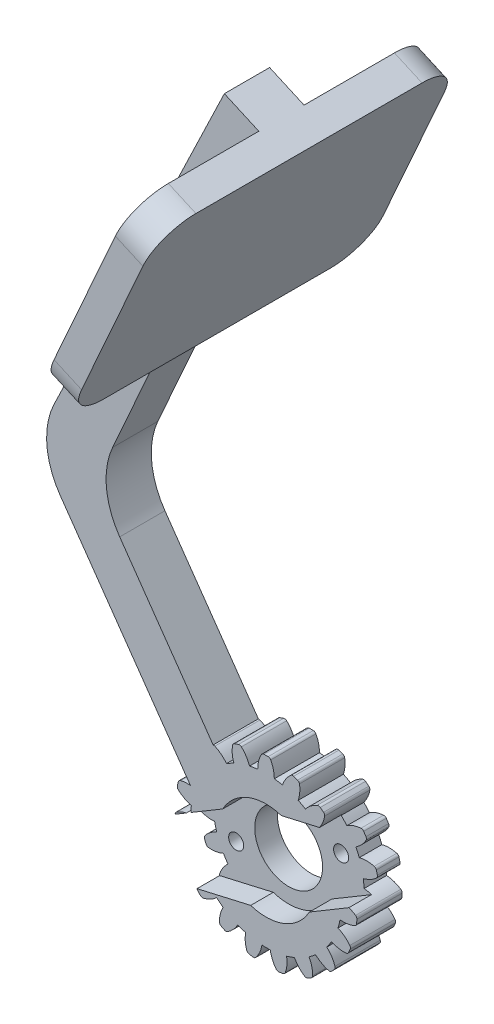
from build123d import *

# Parameters (mm, degrees)
SKETCH1_R                = 1.5
BOSS_EXTRUDE1_DEPTH      = 6
CIRPATTERN1_COUNT        = 19
BOSS_EXTRUDE2_DEPTH      = 6
SKETCH4_R                = 1.5
CUT_EXTRUDE1_DEPTH       = 3
SKETCH5_R                = 4.5
CUT_EXTRUDE2_DEPTH       = 91.375157354
CUT_EXTRUDE2_DEPTH_BACK  = 91.375157354
SKETCH6_R                = 1
CUT_EXTRUDE3_DEPTH       = 91.225656364
CUT_EXTRUDE3_DEPTH_BACK  = 91.225656364
BOSS_EXTRUDE3_DEPTH      = 3
BOSS_EXTRUDE3_DEPTH_BACK = 1


with BuildPart() as part:
    # Sketch1 → Boss-Extrude1 (new body)
    with BuildSketch(Plane.XY):
        with BuildLine():
            ThreePointArc((-1.1, 9.939315872), (0, -10), (1.1, 9.939315872))
            add(Edge.make_bspline(
                [(0.617746857, 11.864626423), (0.963605173, 11.235441628), (1.059124761, 10.632766051), (1.1, 9.939315872)],
                knots=[0.104246354, 0.104246354, 0.104246354, 0.104246354, 1, 1, 1, 1], degree=3))
            ThreePointArc((0.617746857, 11.864626423), (0.474766739, 12.013880626), (0.276370143, 12.071836834))
            ThreePointArc((0.276370143, 12.071836834), (0, 12.075), (-0.276370142, 12.071836834))
            ThreePointArc((-0.276370142, 12.071836834), (-0.474766738, 12.013880627), (-0.617746856, 11.864626423))
            add(Edge.make_bspline(
                [(-0.617746856, 11.864626423), (-0.934550755, 11.28829737), (-1.120724213, 10.60048866), (-1.1, 9.939315872)],
                knots=[0.104246354, 0.104246354, 0.104246354, 0.104246354, 1, 1, 1, 1], degree=3))
        make_face()
        Circle(SKETCH1_R, mode=Mode.SUBTRACT)
    boss_extrude1 = extrude(amount=BOSS_EXTRUDE1_DEPTH)

    # CirPattern1: Boss-Extrude1 ×19 about axis
    cirpattern1_axis = Axis((0, 0, 6), (0, 0, -1))
    for i in range(1, CIRPATTERN1_COUNT):
        add(boss_extrude1.rotate(cirpattern1_axis, i * 360 / CIRPATTERN1_COUNT))

    # Sketch2 → Boss-Extrude2 (add)
    with BuildSketch(Plane.XY.offset(6)):
        with BuildLine():
            Line((-2.585087734, 3.441458618), (-19.415123668, 27.47724089))
            ThreePointArc((-19.415123668, 27.47724089), (-21.177565208, 32.254547728), (-20.359057801, 37.280371684))
            Line((-20.359057801, 37.280371684), (-0.044775905, 82.906995859))
            Line((-0.044775905, 82.906995859), (-5.52604865, 85.347415718))
            Line((-5.52604865, 85.347415718), (-28.123905723, 38.351095908))
            ThreePointArc((-28.123905723, 38.351095908), (-29.07858682, 33.20520575), (-27.303161981, 28.281846311))
            Line((-27.303161981, 28.281846311), (-7.5, 0))
            Line((-7.5, 0), (-2.585087734, 3.441458618))
        make_face()
    extrude(amount=-BOSS_EXTRUDE2_DEPTH)

    # Sketch4 → Cut-Extrude1 (cut)
    with BuildSketch(Plane.XY.offset(6)):
        with BuildLine():
            ThreePointArc((-2.034530077, -6.173385405), (2.420414621, -6.032544493), (5.737256394, -3.055141415))
            Line((5.737256394, -3.055141415), (10.989669758, 0.075054714))
            add(Edge.make_bspline(
                [(10.989669758, 0.075054714), (10.66744888, 0.187695941), (10.330615167, 0.258277336), (9.996205349, 0.275460743)],
                knots=[0.546568193, 0.546568193, 0.546568193, 0.546568193, 1, 1, 1, 1], degree=3))
            ThreePointArc((9.996205349, 0.275460743), (9.96584493, 0.825793455), (9.905209485, 1.373617506))
            add(Edge.make_bspline(
                [(11.653219898, 2.31374963), (11.128191187, 1.82401875), (10.567405996, 1.583473928), (9.905209485, 1.373617506)],
                knots=[0.104246354, 0.104246354, 0.104246354, 0.104246354, 1, 1, 1, 1], degree=3))
            ThreePointArc((11.653219898, 2.31374963), (11.762807418, 2.488994335), (11.770286696, 2.695547456))
            ThreePointArc((11.770286696, 2.695547456), (11.705508211, 2.964237257), (11.634596978, 3.231374035))
            ThreePointArc((11.634596978, 3.231374035), (11.52971073, 3.409472341), (11.349924122, 3.511437564))
            add(Edge.make_bspline(
                [(11.349924122, 3.511437564), (10.713459826, 3.677066929), (10.000994996, 3.688696473), (9.365141414, 3.506298091)],
                knots=[0.104246354, 0.104246354, 0.104246354, 0.104246354, 1, 1, 1, 1], degree=3))
            ThreePointArc((9.365141414, 3.506298091), (9.157733267, 4.016954247), (8.922505039, 4.515407383))
            add(Edge.make_bspline(
                [(10.270543024, 5.972178608), (9.932977174, 5.338506155), (9.480681647, 4.928908061), (8.922505039, 4.515407383)],
                knots=[0.104246354, 0.104246354, 0.104246354, 0.104246354, 1, 1, 1, 1], degree=3))
            ThreePointArc((10.270543024, 5.972178608), (10.317290928, 6.173511082), (10.257297269, 6.371301102))
            ThreePointArc((10.257297269, 6.371301102), (10.108785225, 6.604399009), (9.954976988, 6.83403674))
            ThreePointArc((9.954976988, 6.83403674), (9.797945341, 6.968428679), (9.594792013, 7.006492529))
            add(Edge.make_bspline(
                [(9.594792013, 7.006492529), (8.939033341, 6.956488019), (8.261395715, 6.73615049), (7.719219091, 6.357173635)],
                knots=[0.104246354, 0.104246354, 0.104246354, 0.104246354, 1, 1, 1, 1], degree=3))
            ThreePointArc((7.719219091, 6.357173635), (7.357239107, 6.772815716), (6.972908724, 7.167882806))
            add(Edge.make_bspline(
                [(7.084072765, 7.332751711), (7.04798882, 7.278022576), (7.010909437, 7.223130061), (6.972908724, 7.167882806)],
                knots=[0.913533389, 0.913533389, 0.913533389, 0.913533389, 1, 1, 1, 1], degree=3))
            Line((7.084072765, 7.332751711), (2.034530077, 6.173385405))
            ThreePointArc((2.034530077, 6.173385405), (-2.420414621, 6.032544493), (-5.737256394, 3.055141415))
            Line((-5.737256394, 3.055141415), (-9.986319648, 0.522895679))
            ThreePointArc((-9.986319648, 0.522895679), (-9.992028439, 0.399208812), (-9.996205349, 0.275460743))
            add(Edge.make_bspline(
                [(-10.57273532, 0.173418983), (-10.386903226, 0.214702242), (-10.195544231, 0.247054329), (-9.996205349, 0.275460743)],
                knots=[0.740356392, 0.740356392, 0.740356392, 0.740356392, 1, 1, 1, 1], degree=3))
            Line((-10.57273532, 0.173418983), (-12.053969281, -0.709328145))
            ThreePointArc((-12.053969281, -0.709328145), (-12.053744598, -0.71539522), (-12.053427856, -0.721458186))
            ThreePointArc((-12.053427856, -0.721458186), (-12.033757753, -0.997145596), (-12.007782925, -1.272310582))
            ThreePointArc((-12.007782925, -1.272310582), (-11.933641207, -1.465243568), (-11.773089577, -1.595410022))
            add(Edge.make_bspline(
                [(-11.773089577, -1.595410022), (-11.172567522, -1.863538998), (-10.471733944, -1.992277787), (-9.814530789, -1.917025141)],
                knots=[0.104246354, 0.104246354, 0.104246354, 0.104246354, 1, 1, 1, 1], degree=3))
            ThreePointArc((-9.814530789, -1.917025141), (-9.694002659, -2.454854871), (-9.544025328, -2.985227051))
            add(Edge.make_bspline(
                [(-11.113454495, -4.200250055), (-10.676193545, -3.630781581), (-10.162649109, -3.301215268), (-9.544025328, -2.985227051)],
                knots=[0.104246354, 0.104246354, 0.104246354, 0.104246354, 1, 1, 1, 1], degree=3))
            ThreePointArc((-11.113454495, -4.200250055), (-11.192703054, -4.391142164), (-11.166082798, -4.596109218))
            ThreePointArc((-11.166082798, -4.596109218), (-11.057962919, -4.850472252), (-10.944049555, -5.102294028))
            ThreePointArc((-10.944049555, -5.102294028), (-10.811279801, -5.260699595), (-10.617162323, -5.331682243))
            add(Edge.make_bspline(
                [(-10.617162323, -5.331682243), (-9.962116873, -5.390294059), (-9.257454975, -5.284497135), (-8.660295394, -4.999928369)],
                knots=[0.104246354, 0.104246354, 0.104246354, 0.104246354, 1, 1, 1, 1], degree=3))
            ThreePointArc((-8.660295394, -4.999928369), (-8.371664783, -5.469481581), (-8.057602071, -5.922419173))
            add(Edge.make_bspline(
                [(-8.057602071, -5.922419173), (-8.540105904, -6.422153091), (-8.918815079, -6.900610197), (-9.147477913, -7.581201697)],
                knots=[0.249403928, 0.249403928, 0.249403928, 0.249403928, 1.145157574, 1.145157574, 1.145157574, 1.145157574], degree=3))
            ThreePointArc((-9.147477913, -7.581201697), (-9.168047244, -7.694199594), (-9.155658882, -7.808384316))
            Line((-9.155658882, -7.808384316), (-2.034530077, -6.173385405))
        make_face()
        Circle(SKETCH4_R, mode=Mode.SUBTRACT)
    extrude(amount=-CUT_EXTRUDE1_DEPTH, mode=Mode.SUBTRACT)

    # Sketch5 → Cut-Extrude2 (cut, two sides)
    with BuildSketch(Plane(origin=(0, 0, 0), x_dir=(-1, 0, 0), z_dir=(0, 0, -1))) as cut_extrude2_sk:
        with Locations(Location((0, 0, 0), (0, 0, 180))):
            Circle(SKETCH5_R)
    extrude(amount=CUT_EXTRUDE2_DEPTH, mode=Mode.SUBTRACT)
    extrude(cut_extrude2_sk.sketch, amount=-CUT_EXTRUDE2_DEPTH_BACK, mode=Mode.SUBTRACT)

    # Sketch6 → Cut-Extrude3 (cut, two sides)
    with BuildSketch(Plane.XY.offset(3)) as cut_extrude3_sk:
        with Locations((-6.960628261, -2.792786102)):
            Circle(SKETCH6_R)
        with Locations((6.960628261, 2.792786102)):
            Circle(SKETCH6_R)
    extrude(amount=CUT_EXTRUDE3_DEPTH, mode=Mode.SUBTRACT)
    extrude(cut_extrude3_sk.sketch, amount=-CUT_EXTRUDE3_DEPTH_BACK, mode=Mode.SUBTRACT)

    # Sketch7 → Boss-Extrude3 (add, two sides)
    with BuildSketch(Plane(origin=(-30.843320901, 13.732331215, 0), x_dir=(0, 0, -1), z_dir=(0.9135454576426005, -0.40673664307580126, 0))) as boss_extrude3_sk:
        with BuildLine():
            Line((-18, 45.721097473), (12, 45.721097473))
            ThreePointArc((12, 45.721097473), (15.535533906, 47.185563567), (17, 50.721097473))
            Line((17, 50.721097473), (17, 70.721097473))
            ThreePointArc((17, 70.721097473), (15.535533906, 74.256631379), (12, 75.721097473))
            Line((12, 75.721097473), (-18, 75.721097473))
            ThreePointArc((-18, 75.721097473), (-21.535533906, 74.256631379), (-23, 70.721097473))
            Line((-23, 70.721097473), (-23, 50.721097473))
            ThreePointArc((-23, 50.721097473), (-21.535533906, 47.185563567), (-18, 45.721097473))
        make_face()
    extrude(amount=BOSS_EXTRUDE3_DEPTH)
    extrude(boss_extrude3_sk.sketch, amount=-BOSS_EXTRUDE3_DEPTH_BACK)


solid = part.part
